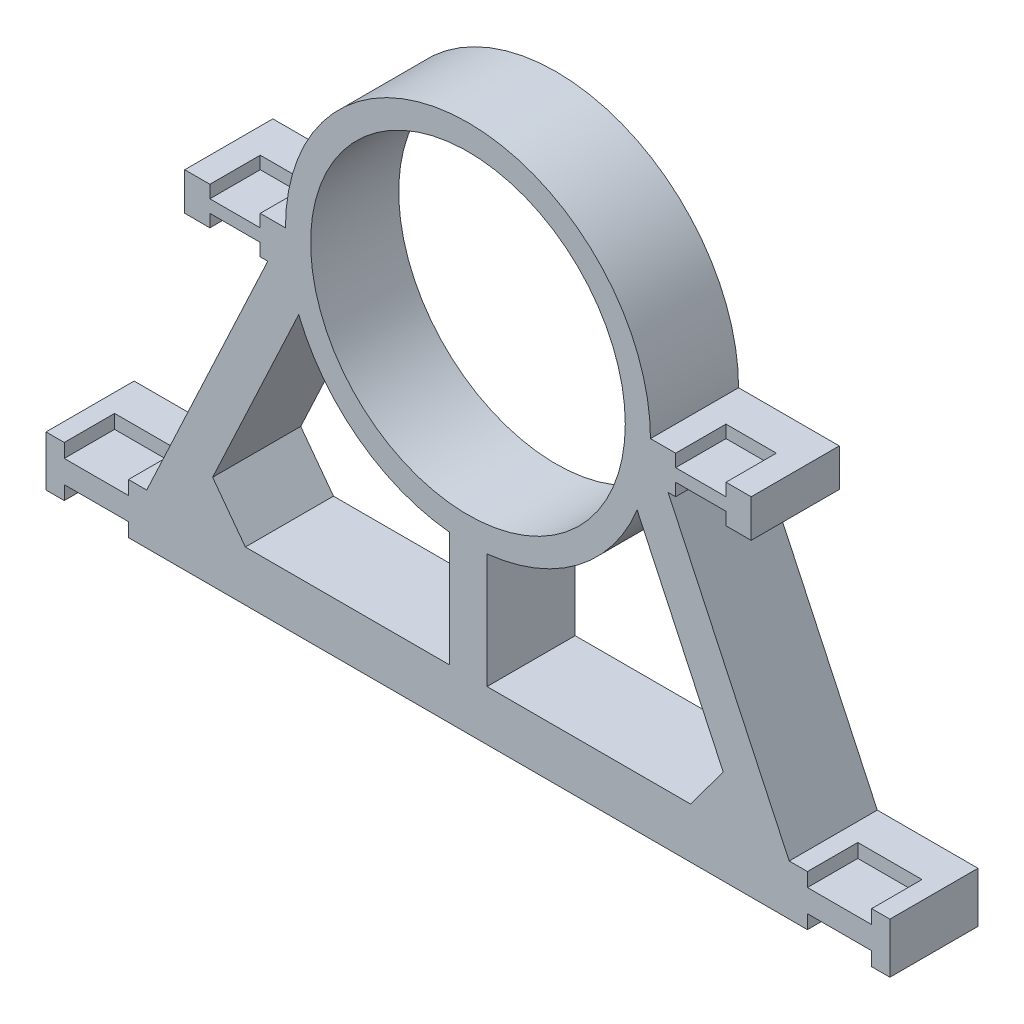
from build123d import *

# Parameters (mm, degrees)
SKETCH1_R            = 62.5
BOSS_EXTRUDE8_DEPTH  = 35
BOSS_EXTRUDE9_REACH  = 192.245
SKETCH2_W            = 15
SKETCH2_H            = 35
SKETCH10_W           = 35
SKETCH10_H           = 15
BOSS_EXTRUDE12_DEPTH = 40
SKETCH6_W            = 35
SKETCH6_H            = 15
BOSS_EXTRUDE10_DEPTH = 40
SKETCH11_W           = 20
SKETCH11_H           = 5
SKETCH11_W_2         = 25.5
SKETCH11_H_2         = 5.5
CUT_EXTRUDE1_DEPTH   = 20


with BuildPart() as part:
    # Sketch1 → Boss-Extrude8 (new body)
    with BuildSketch(Plane.XY):
        with BuildLine():
            Line((127.600917431, -117.745016448), (72.5, 0))
            ThreePointArc((72.5, 0), (0, 72.5), (-72.5, 0))
            Line((-72.5, 0), (-127.600917431, -117.745016448))
            Line((-127.600917431, -117.745016448), (-167.600917431, -117.745016448))
            Line((-167.600917431, -117.745016448), (-167.600917431, -137.745016448))
            Line((-167.600917431, -137.745016448), (167.600917431, -137.745016448))
            Line((167.600917431, -137.745016448), (167.600917431, -117.745016448))
            Line((167.600917431, -117.745016448), (127.600917431, -117.745016448))
        make_face()
        with BuildLine():
            ThreePointArc((-67.21559633, -27.171926873), (0, -72.5), (67.21559633, -27.171926873))
            Line((67.21559633, -27.171926873), (101.417450928, -100.25778678))
            Line((101.417450928, -100.25778678), (88.408256881, -117.745016448))
            Line((88.408256881, -117.745016448), (-88.408256881, -117.745016448))
            Line((-88.408256881, -117.745016448), (-101.417450928, -100.25778678))
            Line((-101.417450928, -100.25778678), (-67.21559633, -27.171926873))
        make_face(mode=Mode.SUBTRACT)
        Circle(SKETCH1_R, mode=Mode.SUBTRACT)
    extrude(amount=BOSS_EXTRUDE8_DEPTH)

    # Sketch2 → Boss-Extrude9 (add, up to next)
    with BuildSketch(Plane(origin=(0, -117.745016448, 0), x_dir=(1, 0, 0), z_dir=(0, 1, 0)), mode=Mode.PRIVATE) as boss_extrude9_sk1:
        with Locations((0.093911399, -17.5)):
            Rectangle(SKETCH2_W, SKETCH2_H)
    boss_extrude9_tool1 = extrude(boss_extrude9_sk1.sketch, amount=BOSS_EXTRUDE9_REACH, mode=Mode.PRIVATE) - part.part
    add(boss_extrude9_tool1.solids().sort_by_distance((0.093911, -117.745016, 17.5))[0])

    # Sketch10 → Boss-Extrude12 (add)
    with BuildSketch(Plane(origin=(-72.5, 0, 0), x_dir=(0, 0, -1), z_dir=(1, 0, 0))):
        with Locations((-17.5, -7.5)):
            Rectangle(SKETCH10_W, SKETCH10_H)
    extrude(amount=-BOSS_EXTRUDE12_DEPTH)

    # Sketch6 → Boss-Extrude10 (add)
    with BuildSketch(Plane(origin=(72.5, 0, 0), x_dir=(0, 0, -1), z_dir=(1, 0, 0))):
        with Locations((-17.5, -7.5)):
            Rectangle(SKETCH6_W, SKETCH6_H)
    extrude(amount=BOSS_EXTRUDE10_DEPTH)

    # Sketch11 → Cut-Extrude1 (cut)
    with BuildSketch(Plane.XY.offset(35)):
        with Locations((-92.5, -2.5)):
            Rectangle(SKETCH11_W, SKETCH11_H)
        with Locations((-92.5, -12.5)):
            Rectangle(SKETCH11_W, SKETCH11_H)
        with Locations((92.5, -2.5)):
            Rectangle(SKETCH11_W, SKETCH11_H)
        with Locations((92.5, -12.5)):
            Rectangle(SKETCH11_W, SKETCH11_H)
        with Locations((147.600917431, -120.495016448)):
            Rectangle(SKETCH11_W_2, SKETCH11_H_2)
        with Locations((147.600917431, -134.995016448)):
            Rectangle(SKETCH11_W_2, SKETCH11_H_2)
        with Locations((-147.600917431, -120.495016448)):
            Rectangle(SKETCH11_W_2, SKETCH11_H_2)
        with Locations((-147.600917431, -134.995016448)):
            Rectangle(SKETCH11_W_2, SKETCH11_H_2)
    extrude(amount=-CUT_EXTRUDE1_DEPTH, mode=Mode.SUBTRACT)


solid = part.part
